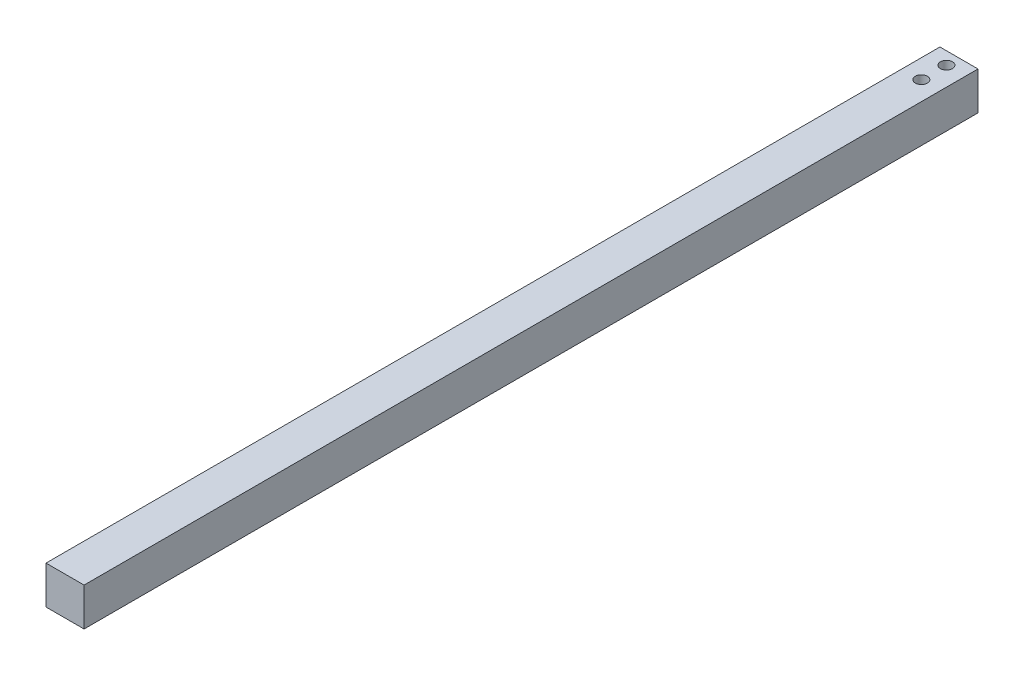
from build123d import *

# Parameters (mm, degrees)
SKETCH1_W               = 19
SKETCH1_H               = 19
BOSS_EXTRUDE1_DEPTH     = 446
CUT_EXTRUDE1_DEPTH      = 9
CUT_EXTRUDE2_DEPTH      = 1
CUT_EXTRUDE2_DEPTH_BACK = 20


with BuildPart() as part:
    # Sketch1 → Boss-Extrude1 (new body)
    with BuildSketch(Plane.XY):
        Rectangle(SKETCH1_W, SKETCH1_H)
    extrude(amount=BOSS_EXTRUDE1_DEPTH)

    # Sketch2 → Cut-Extrude1 (cut)
    with BuildSketch(Plane.XZ.offset(9.5)):
        with BuildLine():
            ThreePointArc((-4, 442.25), (-6, 444.25), (-8, 442.25))
            Line((-8, 442.25), (-4, 442.25))
        make_face()
        with BuildLine():
            Line((-4, 442.25), (-8, 442.25))
            ThreePointArc((-8, 442.25), (-6, 440.25), (-4, 442.25))
        make_face()
        with BuildLine():
            ThreePointArc((8, 442.25), (6, 444.25), (4, 442.25))
            Line((4, 442.25), (6, 442.25))
            Line((6, 442.25), (8, 442.25))
        make_face()
        with BuildLine():
            Line((6, 442.25), (4, 442.25))
            ThreePointArc((4, 442.25), (6, 440.25), (8, 442.25))
            Line((8, 442.25), (6, 442.25))
        make_face()
    extrude(amount=-CUT_EXTRUDE1_DEPTH, mode=Mode.SUBTRACT)

    # Sketch3 → Cut-Extrude2 (cut, two sides)
    with BuildSketch(Plane(origin=(0, 9.5, 0), x_dir=(1, 0, 0), z_dir=(0, 1, 0))) as cut_extrude2_sk:
        with BuildLine():
            ThreePointArc((3, -18.75), (2.121320344, -16.628679656), (0, -15.75))
            Line((0, -15.75), (0, -21.75))
            ThreePointArc((0, -21.75), (2.121320344, -20.871320344), (3, -18.75))
        make_face()
        with BuildLine():
            Line((0, -21.75), (0, -15.75))
            ThreePointArc((0, -15.75), (-3, -18.75), (0, -21.75))
        make_face()
        with BuildLine():
            ThreePointArc((3, -6.25), (2.121320344, -4.128679656), (0, -3.25))
            Line((0, -3.25), (0, -9.25))
            ThreePointArc((0, -9.25), (2.121320344, -8.371320344), (3, -6.25))
        make_face()
        with BuildLine():
            Line((0, -9.25), (0, -3.25))
            ThreePointArc((0, -3.25), (-3, -6.25), (0, -9.25))
        make_face()
    extrude(amount=CUT_EXTRUDE2_DEPTH, mode=Mode.SUBTRACT)
    extrude(cut_extrude2_sk.sketch, amount=-CUT_EXTRUDE2_DEPTH_BACK, mode=Mode.SUBTRACT)


solid = part.part
